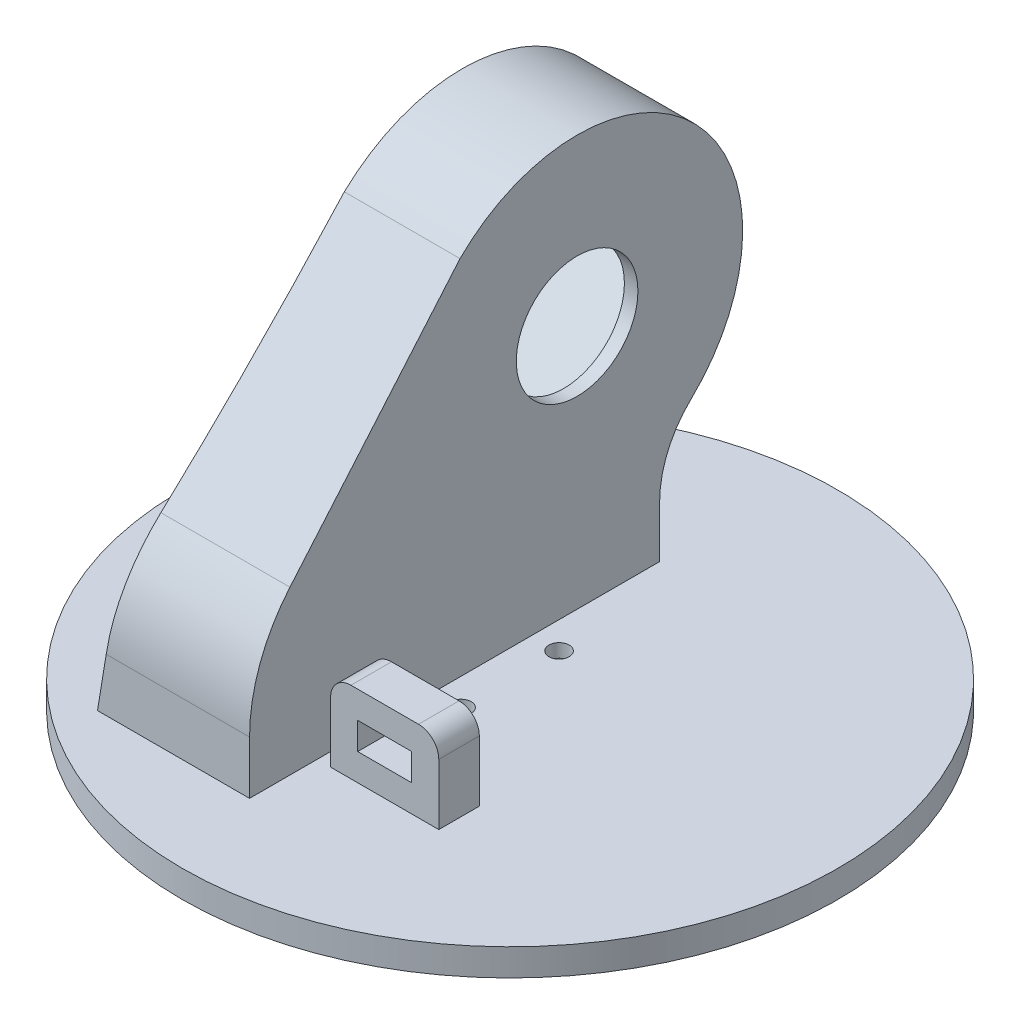
from build123d import *

# Parameters (mm, degrees)
SKETCH2_R                = 48.5
BOSS_EXTRUDE1_DEPTH      = 4
SKETCH4_R                = 1.5
CUT_EXTRUDE2_DEPTH       = 5
SKETCH5_R                = 3.75
CUT_EXTRUDE3_DEPTH       = 1.5
BOSS_EXTRUDE2_DEPTH      = 14
CUT_EXTRUDE5_REACH       = 44.5
SKETCH9_R                = 1.3
CUT_EXTRUDE6_DEPTH       = 7.5
CUT_EXTRUDE9_REACH       = 46.5
SKETCH11_R               = 9
BOSS_EXTRUDE7_DEPTH      = 9
BOSS_EXTRUDE7_DEPTH_BACK = 14
BOSS_EXTRUDE10_DEPTH     = 9
SKETCH27_W               = 16
SKETCH27_H               = 6
BOSS_EXTRUDE11_DEPTH     = 12
FILLET6_R                = 3
CUT_EXTRUDE16_REACH      = 75.05
SKETCH28_W               = 8
SKETCH28_H               = 4
CUT_EXTRUDE17_DEPTH      = 49.5
CUT_EXTRUDE17_DEPTH_BACK = 49.5
CUT_EXTRUDE19_DEPTH      = 2


with BuildPart() as part:
    # Sketch2 → Boss-Extrude1 (new body)
    with BuildSketch(Plane(origin=(0, 0, 0), x_dir=(1, 0, 0), z_dir=(0, 1, 0))):
        Circle(SKETCH2_R)
    extrude(amount=BOSS_EXTRUDE1_DEPTH)

    # Sketch4 → Cut-Extrude2 (cut, through all)
    with BuildSketch(Plane.XZ):
        with Locations((0, 7.25)):
            Circle(SKETCH4_R)
        with Locations((0, -7.25)):
            Circle(SKETCH4_R)
    extrude(amount=-CUT_EXTRUDE2_DEPTH, mode=Mode.SUBTRACT)

    # Sketch5 → Cut-Extrude3 (cut)
    with BuildSketch(Plane.XZ):
        Circle(SKETCH5_R)
    extrude(amount=-CUT_EXTRUDE3_DEPTH, mode=Mode.SUBTRACT)

    # Sketch7 → Boss-Extrude2 (add)
    with BuildSketch(Plane(origin=(-4, 0, 0), x_dir=(0, 0, -1), z_dir=(1, 0, 0))):
        with BuildLine():
            Line((23.129947874, 4), (23.129947874, 11.644549616))
            ThreePointArc((23.129947874, 11.644549616), (24.589048403, 18.743749901), (28.729797284, 24.692011643))
            ThreePointArc((28.729797284, 24.692011643), (29.313383054, 55.284736897), (-1.284289494, 55.479275971))
            Line((-1.284289494, 55.479275971), (-27.227315747, 29.536249718))
            ThreePointArc((-27.227315747, 29.536249718), (-32.64663453, 21.425665997), (-34.549646217, 11.858580188))
            Line((-34.549646217, 11.858580188), (-34.549646217, 4))
            Line((-34.549646217, 4), (23.129947874, 4))
        make_face()
    extrude(amount=-BOSS_EXTRUDE2_DEPTH)

    # Sketch8 → Cut-Extrude5 (cut, up to next)
    with BuildSketch(Plane(origin=(-6, 0, 0), x_dir=(0, 0, -1), z_dir=(1, 0, 0)), mode=Mode.PRIVATE) as cut_extrude5_sk1:
        Polygon((-15.249648422, 25.957567857), (13.741729607, 54.948945886), (28.590972012, 40.099703481), (-0.400406017, 11.108325452), align=None)
    cut_extrude5_tool1 = extrude(cut_extrude5_sk1.sketch, amount=-CUT_EXTRUDE5_REACH, mode=Mode.PRIVATE) & part.part
    add(cut_extrude5_tool1.solids().sort_by_distance((-6, 33.028636, -6.670662))[0], mode=Mode.SUBTRACT)

    # Sketch9 → Cut-Extrude6 (cut)
    with BuildSketch(Plane.ZY.offset(18)):
        with Locations((-20.105690637, 53.534732323)):
            Circle(SKETCH9_R)
        with Locations((-27.176758449, 46.463664511)):
            Circle(SKETCH9_R)
        with Locations((6.764367048, 12.522539014)):
            Circle(SKETCH9_R)
        with Locations((13.83543486, 19.593606826)):
            Circle(SKETCH9_R)
    extrude(amount=-CUT_EXTRUDE6_DEPTH, mode=Mode.SUBTRACT)

    # Sketch11 → Cut-Extrude9 (cut, up to next)
    with BuildSketch(Plane(origin=(-4, 0, 0), x_dir=(0, 0, -1), z_dir=(1, 0, 0)), mode=Mode.PRIVATE) as cut_extrude9_sk1:
        with Locations((13.918506302, 40.276480176)):
            Circle(SKETCH11_R)
    cut_extrude9_tool1 = extrude(cut_extrude9_sk1.sketch, amount=-CUT_EXTRUDE9_REACH, mode=Mode.PRIVATE) & part.part
    add(cut_extrude9_tool1.solids().sort_by_distance((-4, 40.27648, -13.918506))[0], mode=Mode.SUBTRACT)

    # Sketch17 → Boss-Extrude7 (add, two sides)
    with BuildSketch(Plane.ZY.offset(18)) as boss_extrude7_sk:
        with BuildLine():
            ThreePointArc((34.549646217, 11.858580188), (33.008342843, 20.500891953), (28.574482006, 28.077569775))
            ThreePointArc((28.574482006, 28.077569775), (27.915386359, 28.820289685), (27.227315747, 29.536249718))
            Line((27.227315747, 29.536249718), (1.284289494, 55.479275971))
            Line((1.284289494, 55.479275971), (26.295003593, 26.127182305))
            ThreePointArc((26.295003593, 26.127182305), (30.194232218, 19.461281607), (31.549646217, 11.858580188))
            Line((31.549646217, 11.858580188), (31.549646217, 4))
            Line((31.549646217, 4), (34.549646217, 4))
            Line((34.549646217, 4), (34.549646217, 11.858580188))
        make_face()
        with BuildLine():
            Line((28.574482006, 28.077569775), (3.405609837, 57.600596315))
            ThreePointArc((3.405609837, 57.600596315), (-31.461505391, 57.378912253), (-30.796489049, 22.517434639))
            ThreePointArc((-30.796489049, 22.517434639), (-27.345864981, 17.560549854), (-26.129947874, 11.644549616))
            Line((-26.129947874, 11.644549616), (-26.129947874, 4))
            Line((-26.129947874, 4), (-23.129947874, 4))
            Line((-23.129947874, 4), (-23.129947874, 11.644549616))
            ThreePointArc((-23.129947874, 11.644549616), (-24.589048403, 18.743749901), (-28.729797284, 24.692011643))
            ThreePointArc((-28.729797284, 24.692011643), (-29.313383054, 55.284736897), (1.284289494, 55.479275971))
            Line((1.284289494, 55.479275971), (27.227315747, 29.536249718))
            ThreePointArc((27.227315747, 29.536249718), (27.915386359, 28.820289685), (28.574482006, 28.077569775))
        make_face()
    extrude(amount=BOSS_EXTRUDE7_DEPTH)
    extrude(boss_extrude7_sk.sketch, amount=-BOSS_EXTRUDE7_DEPTH_BACK)

    # Sketch25 → Boss-Extrude10 (add)
    with BuildSketch(Plane.ZY.offset(18)):
        with BuildLine():
            ThreePointArc((-28.729797284, 24.692011643), (-24.589048403, 18.743749901), (-23.129947874, 11.644549616))
            Line((-23.129947874, 11.644549616), (-23.129947874, 4))
            Line((-23.129947874, 4), (-15.129947874, 4))
            add(Edge.make_bspline(
                [(-28.729797284, 24.692011643), (-21.954867515, 18.253200081), (-19.09405247, 12.798017691), (-15.129947874, 4)],
                knots=[0, 0, 0, 0, 1, 1, 1, 1], degree=3))
        make_face()
        with BuildLine():
            add(Edge.make_bspline(
                [(11.751619577, 43.19501844), (26.551255916, 25.8264495), (25.549646217, 4)],
                knots=[0, 0, 0, 1, 1, 1], degree=2))
            Line((25.549646217, 4), (31.549646217, 4))
            Line((31.549646217, 4), (31.549646217, 11.858580188))
            ThreePointArc((31.549646217, 11.858580188), (30.194232218, 19.461281607), (26.295003593, 26.127182305))
            Line((26.295003593, 26.127182305), (11.751619577, 43.19501844))
        make_face()
    extrude(amount=BOSS_EXTRUDE10_DEPTH)

    # Sketch27 → Boss-Extrude11 (add)
    with BuildSketch(Plane(origin=(0, 4, 0), x_dir=(1, 0, 0), z_dir=(0, 1, 0))):
        with Locations((6, -21.549646217)):
            Rectangle(SKETCH27_W, SKETCH27_H)
    extrude(amount=BOSS_EXTRUDE11_DEPTH)

    # Fillet6
    fillet6_edges = [part.edges().sort_by_distance(p)[0] for p in [
        (-2, 16, 21.549646217),
        (14, 16, 21.549646217),
    ]]
    fillet(fillet6_edges, radius=FILLET6_R)

    # Sketch28 → Cut-Extrude16 (cut, up to next)
    with BuildSketch(Plane.XY.offset(24.549646217), mode=Mode.PRIVATE) as cut_extrude16_sk1:
        with Locations((6, 10)):
            Rectangle(SKETCH28_W, SKETCH28_H)
    cut_extrude16_tool1 = extrude(cut_extrude16_sk1.sketch, amount=-CUT_EXTRUDE16_REACH, mode=Mode.PRIVATE) & part.part
    add(cut_extrude16_tool1.solids().sort_by_distance((6, 10, 24.549646))[0], mode=Mode.SUBTRACT)

    # Sketch29 → Cut-Extrude17 (cut, two sides)
    with BuildSketch(Plane.XY) as cut_extrude17_sk:
        with BuildLine():
            Line((-21, 64.776480176), (-27, 64.776480176))
            Line((-27, 64.776480176), (-27, 4))
            Line((-27, 4), (-26.5, 4))
            add(Edge.make_bspline(
                [(-21, 64.776480176), (-21.220459696, 34.140901434), (-26.5, 4)],
                knots=[0, 0, 0, 1, 1, 1], degree=2))
        make_face()
    extrude(amount=CUT_EXTRUDE17_DEPTH, mode=Mode.SUBTRACT)
    extrude(cut_extrude17_sk.sketch, amount=-CUT_EXTRUDE17_DEPTH_BACK, mode=Mode.SUBTRACT)

    # Sketch30 → Cut-Extrude19 (cut)
    with BuildSketch(Plane.XZ):
        with BuildLine():
            Line((-1.621331548, 6.623828248), (-2.453034191, 6.751779974))
            Line((-2.453034191, 6.751779974), (-4.898074614, 8.235232927))
            Line((-4.898074614, 8.235232927), (-13.834583132, 11.85774614))
            ThreePointArc((-13.834583132, 11.85774614), (-17.526437212, 10.633625847), (-16.906999469, 6.793762058))
            Line((-16.906999469, 6.793762058), (-9.566495717, 0.540699516))
            Line((-9.566495717, 0.540699516), (-7.121455294, -0.942753437))
            Line((-7.121455294, -0.942753437), (-6.623828248, -1.621331548))
            Line((-6.623828248, -1.621331548), (-6.751779974, -2.453034191))
            Line((-6.751779974, -2.453034191), (-8.235232927, -4.898074614))
            Line((-8.235232927, -4.898074614), (-11.85774614, -13.834583132))
            ThreePointArc((-11.85774614, -13.834583132), (-10.633625847, -17.526437212), (-6.793762058, -16.906999469))
            Line((-6.793762058, -16.906999469), (-0.540699516, -9.566495717))
            Line((-0.540699516, -9.566495717), (0.942753437, -7.121455294))
            Line((0.942753437, -7.121455294), (1.621331548, -6.623828248))
            Line((1.621331548, -6.623828248), (2.453034191, -6.751779974))
            Line((2.453034191, -6.751779974), (4.898074614, -8.235232927))
            Line((4.898074614, -8.235232927), (13.834583132, -11.85774614))
            ThreePointArc((13.834583132, -11.85774614), (17.526437212, -10.633625847), (16.906999469, -6.793762058))
            Line((16.906999469, -6.793762058), (9.566495717, -0.540699516))
            Line((9.566495717, -0.540699516), (7.121455294, 0.942753437))
            Line((7.121455294, 0.942753437), (6.623828248, 1.621331548))
            Line((6.623828248, 1.621331548), (6.751779974, 2.453034191))
            Line((6.751779974, 2.453034191), (8.235232927, 4.898074614))
            Line((8.235232927, 4.898074614), (11.85774614, 13.834583132))
            ThreePointArc((11.85774614, 13.834583132), (10.633625847, 17.526437212), (6.793762058, 16.906999469))
            Line((6.793762058, 16.906999469), (0.540699516, 9.566495717))
            Line((0.540699516, 9.566495717), (-0.942753437, 7.121455294))
            Line((-0.942753437, 7.121455294), (-1.621331548, 6.623828248))
        make_face()
    extrude(amount=-CUT_EXTRUDE19_DEPTH, mode=Mode.SUBTRACT)


solid = part.part
